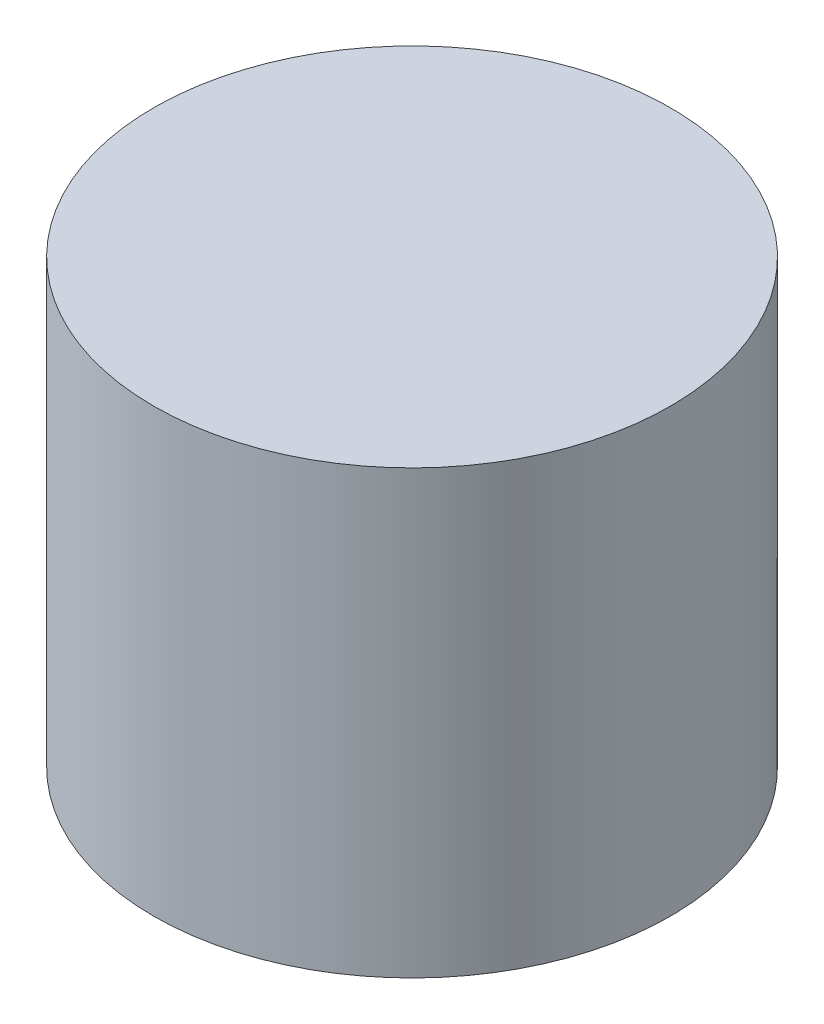
from build123d import *

# Parameters (mm, degrees)
SKETCH1_R           = 5.85
BOSS_EXTRUDE1_DEPTH = 10


with BuildPart() as part:
    # Sketch1 → Boss-Extrude1 (new body)
    with BuildSketch(Plane(origin=(0, 0, 0), x_dir=(1, 0, 0), z_dir=(0, 1, 0))):
        with Locations((35.691000862, -14.792892735)):
            Circle(SKETCH1_R)
    extrude(amount=BOSS_EXTRUDE1_DEPTH)


solid = part.part
